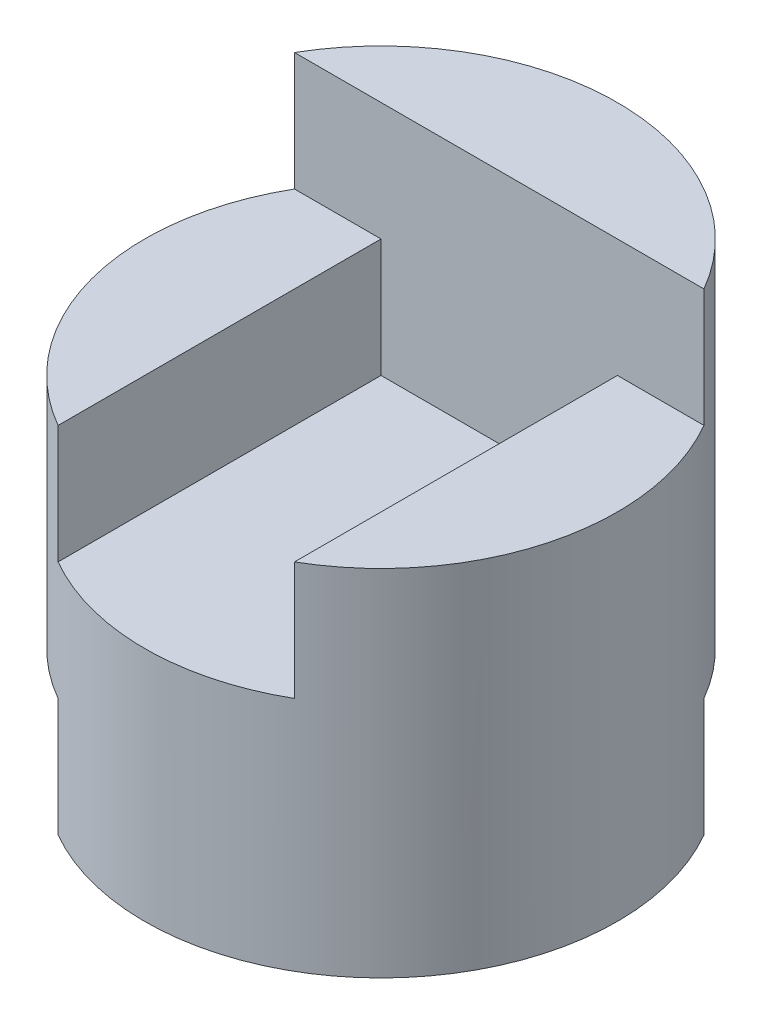
from build123d import *

# Parameters (mm, degrees)
SKETCH1_R               = 2
BOSS_EXTRUDE1_DEPTH     = 4
SKETCH2_W               = 1
SKETCH2_H               = 1
CUT_EXTRUDE4_DEPTH      = 11
CUT_EXTRUDE4_DEPTH_BACK = 1
SKETCH5_W               = 1
SKETCH5_H               = 1
CUT_EXTRUDE5_DEPTH      = 5.5


with BuildPart() as part:
    # Sketch1 → Boss-Extrude1 (new body)
    with BuildSketch(Plane(origin=(0, 0, 0), x_dir=(1, 0, 0), z_dir=(0, 1, 0))):
        Circle(SKETCH1_R)
    extrude(amount=BOSS_EXTRUDE1_DEPTH)

    # Sketch2 → Cut-Extrude4 (cut, two sides)
    with BuildSketch(Plane.XY) as cut_extrude4_sk:
        Polygon((-2, 4), (2, 4), (2, 3), (1, 3), (1, 2), (-1, 2), (-1, 3), (-2, 3), align=None)
        with Locations((-1.5, 0.5)):
            Rectangle(SKETCH2_W, SKETCH2_H)
    extrude(amount=CUT_EXTRUDE4_DEPTH, mode=Mode.SUBTRACT)
    extrude(cut_extrude4_sk.sketch, amount=-CUT_EXTRUDE4_DEPTH_BACK, mode=Mode.SUBTRACT)

    # Sketch5 → Cut-Extrude5 (cut, symmetric)
    with BuildSketch(Plane(origin=(0, 0, 0), x_dir=(0, 0, -1), z_dir=(1, 0, 0))):
        with Locations((1.5, 0.5)):
            Rectangle(SKETCH5_W, SKETCH5_H)
    extrude(amount=CUT_EXTRUDE5_DEPTH, both=True, mode=Mode.SUBTRACT)


solid = part.part
